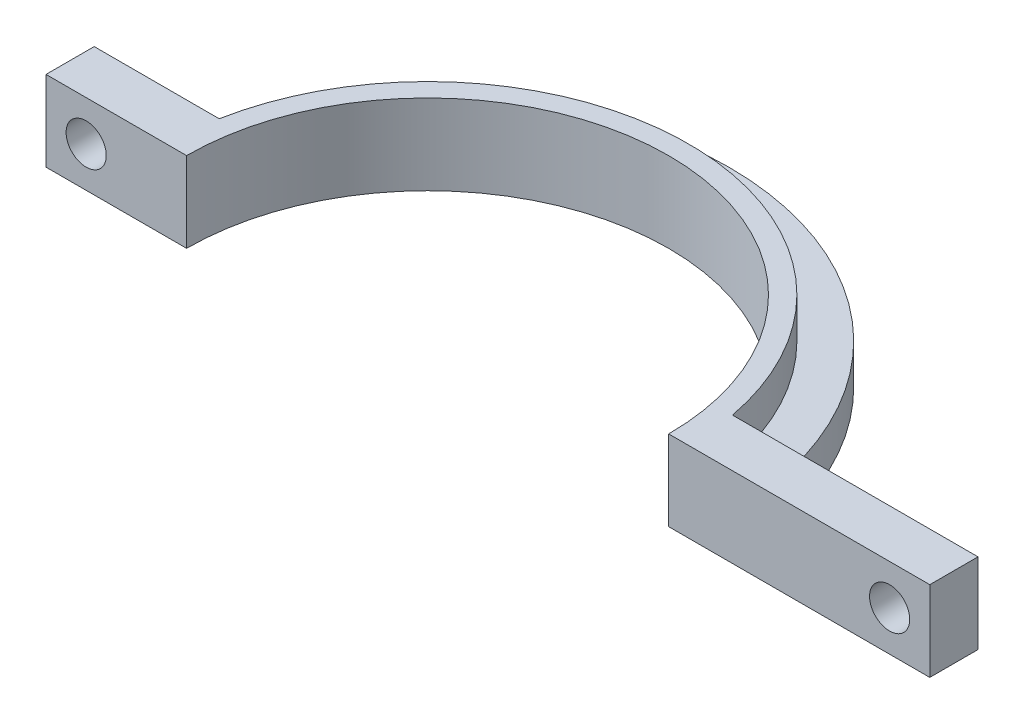
from build123d import *

# Parameters (mm, degrees)
BOSS_EXTRUDE1_DEPTH = 10
SKETCH3_R           = 2.5
CUT_EXTRUDE1_DEPTH  = 10
BOSS_EXTRUDE2_DEPTH = 5


with BuildPart() as part:
    # Sketch1 → Boss-Extrude1 (new body)
    with BuildSketch(Plane(origin=(0, 0, 0), x_dir=(1, 0, 0), z_dir=(0, 1, 0))):
        with BuildLine():
            Line((62.5, 6), (31.941352507, 6))
            ThreePointArc((31.941352507, 6), (0, 32.5), (-31.941352507, 6))
            Line((-31.941352507, 6), (-47.5, 6))
            Line((-47.5, 6), (-47.5, 0))
            Line((-47.5, 0), (-30, 0))
            ThreePointArc((-30, 0), (0, 30), (30, 0))
            Line((30, 0), (62.5, 0))
            Line((62.5, 0), (62.5, 6))
        make_face()
    extrude(amount=BOSS_EXTRUDE1_DEPTH)

    # Sketch3 → Cut-Extrude1 (cut)
    with BuildSketch(Plane.XY):
        with Locations((57.5, 5)):
            Circle(SKETCH3_R)
        with Locations((-42.5, 5)):
            Circle(SKETCH3_R)
    extrude(amount=-CUT_EXTRUDE1_DEPTH, mode=Mode.SUBTRACT)

    # Sketch5 → Boss-Extrude2 (add)
    with BuildSketch(Plane(origin=(0, 0, 0), x_dir=(1, 0, 0), z_dir=(0, 1, 0))):
        with BuildLine():
            ThreePointArc((37.5, 0), (0, 37.5), (-37.5, 0))
            Line((-37.5, 0), (-32.5, 0))
            ThreePointArc((-32.5, 0), (0, 32.5), (32.5, 0))
            Line((32.5, 0), (37.5, 0))
        make_face()
    extrude(amount=BOSS_EXTRUDE2_DEPTH)


solid = part.part
